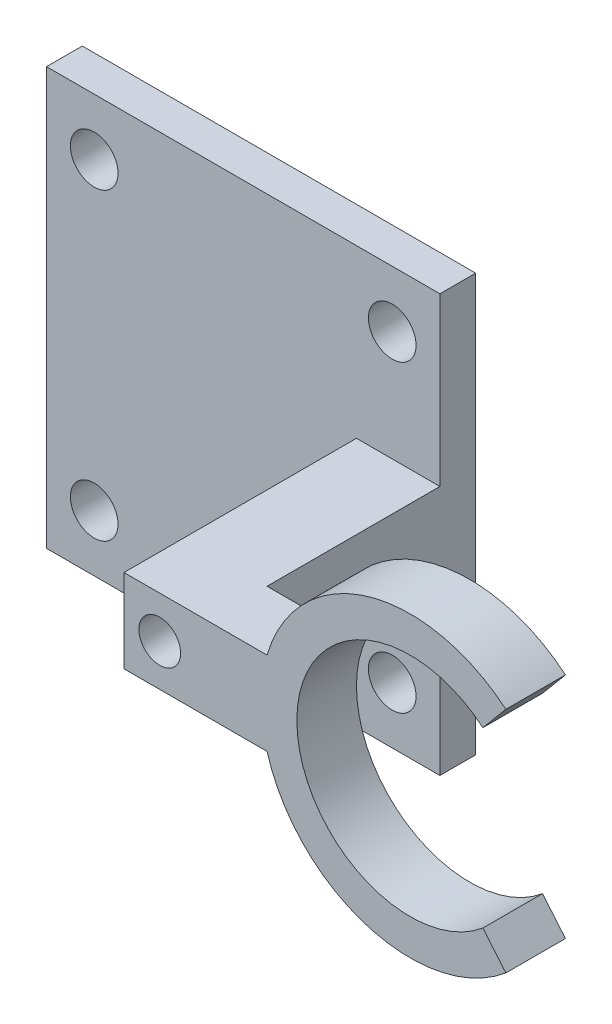
from build123d import *

# Parameters (mm, degrees)
RESSALTO_EXTRUS_O1_DEPTH = 3.5
ESBO_O15_W               = 33
ESBO_O15_H               = 14
ESBO_O15_R               = 2
ESBO_O15_H_2             = 7
RESSALTO_EXTRUS_O2_DEPTH = 3
ESBO_O16_R               = 1.75
CORTE_EXTRUS_O1_DEPTH    = 58.554322166


with BuildPart() as part:
    # Esboço14 → Ressalto-extrusão1 (new, symmetric)
    with BuildSketch(Plane(origin=(0, 0, 0), x_dir=(1, 0, 0), z_dir=(0, 1, 0))):
        Polygon((-12, 2.5), (-17, 2.5), (-17, 20), (-50, 20), (-50, 17), (-24, 17), (-24, -2.5), (-12, -2.5), align=None)
    extrude(amount=RESSALTO_EXTRUS_O1_DEPTH, both=True)

    # Esboço15 → Ressalto-extrusão2 (add)
    with BuildSketch(Plane(origin=(0, 0, -20), x_dir=(-1, 0, 0), z_dir=(0, 0, -1))):
        with Locations((33.5, -10.5)):
            Rectangle(ESBO_O15_W, ESBO_O15_H)
        with Locations((21, -12.75)):
            Circle(ESBO_O15_R, mode=Mode.SUBTRACT)
        with Locations((46, -12.75)):
            Circle(ESBO_O15_R, mode=Mode.SUBTRACT)
        with Locations((33.5, 10.5)):
            Rectangle(ESBO_O15_W, ESBO_O15_H)
        with Locations((21, 12.75)):
            Circle(ESBO_O15_R, mode=Mode.SUBTRACT)
        with Locations((46, 12.75)):
            Circle(ESBO_O15_R, mode=Mode.SUBTRACT)
        with Locations((33.5, 0)):
            Rectangle(ESBO_O15_W, ESBO_O15_H_2)
    extrude(amount=-RESSALTO_EXTRUS_O2_DEPTH)

    # Esboço16 → Corte-extrusão1 (cut, through all)
    with BuildSketch(Plane.XY.offset(2.5)):
        with Locations((-21, 0)):
            Circle(ESBO_O16_R)
    extrude(amount=-CORTE_EXTRUS_O1_DEPTH, mode=Mode.SUBTRACT)

    # Varredura1: sweep along a path in Esboço1
    with BuildLine(Plane.XY) as varredura1_path:
        ThreePointArc((7.070663707, 8.426488874), (-11, 0), (7.070663707, -8.426488874))
    # 3DSketch2 → Varredura1 (sweep)
    with BuildSketch(Plane(origin=(8.034845121, -9.575555539, 2.5), x_dir=(-0.33071149682512846, 0.39412661445355873, -0.8574929257125443), z_dir=(0.7660444431189768, 0.6427876096865409, 3.624573608241852e-15))):
        Polygon((0, 0), (1.543487266, 2.572478777), (5.830951895, 0), (4.287464629, -2.572478777), align=None)
    sweep(path=varredura1_path.line)


solid = part.part
